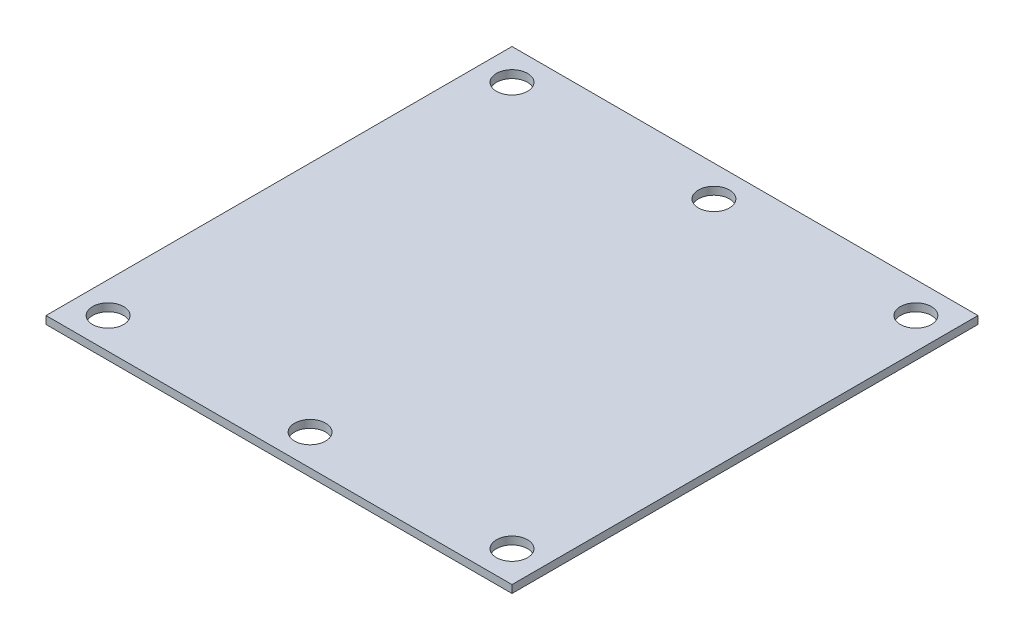
from build123d import *

# Parameters (mm, degrees)
SKETCH1_W                    = 60
SKETCH1_H                    = 60
BOSS_EXTRUDE1_DEPTH          = 1
F_4_0_4_DIAMETER_HOLE1_D     = 4
F_4_0_4_DIAMETER_HOLE1_DEPTH = 1


with BuildPart() as part:
    # Sketch1 → Boss-Extrude1 (new body)
    with BuildSketch(Plane(origin=(0, 0, 0), x_dir=(1, 0, 0), z_dir=(0, 1, 0))):
        Rectangle(SKETCH1_W, SKETCH1_H)
    extrude(amount=BOSS_EXTRUDE1_DEPTH)

    # Ø4.0 (4) Diameter Hole1
    with Locations(Plane(origin=(0, 1, 0), x_dir=(1, 0, 0), z_dir=(0, 1, 0))):
        with Locations((26, 26), (0, 26), (-26, 26), (0, -26), (26, -26), (-26, -26)):
            Hole(F_4_0_4_DIAMETER_HOLE1_D / 2, depth=F_4_0_4_DIAMETER_HOLE1_DEPTH)


solid = part.part
